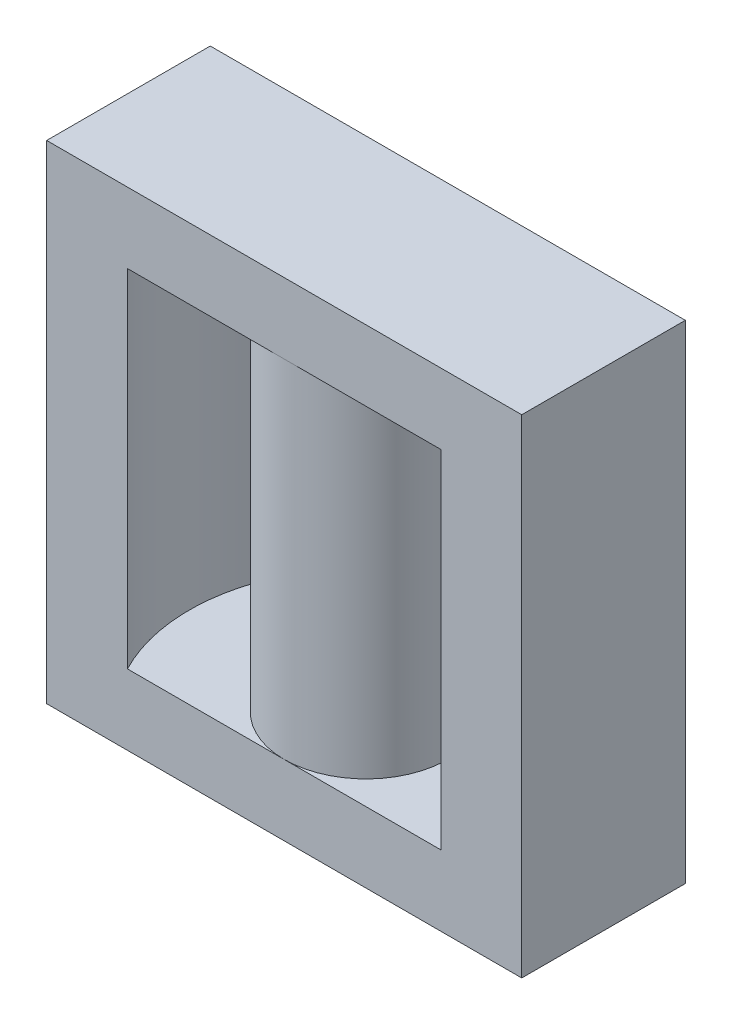
from build123d import *

# Parameters (mm, degrees)
BOSS_EXTRUDE1_DEPTH   = 49.8
SKETCH1_R             = 8.35
BOSS_EXTRUDE1_2_DEPTH = 49.8
BOSS_EXTRUDE1_3_DEPTH = 49.8
SKETCH2_W             = 48.5
SKETCH2_H             = 16.7
BOSS_EXTRUDE2_DEPTH   = 7.2
SKETCH3_W             = 48.5
SKETCH3_H             = 16.7
BOSS_EXTRUDE3_DEPTH   = 7.2


with BuildPart() as part:
    # Sketch1 → Boss-Extrude1 (new body)
    with BuildSketch(Plane(origin=(0, 0, 0), x_dir=(1, 0, 0), z_dir=(0, 1, 0))):
        with BuildLine():
            Line((-16.002499805, 8.35), (-24.25, 8.35))
            Line((-24.25, 8.35), (-24.25, -8.35))
            Line((-24.25, -8.35), (-16.002499805, -8.35))
            ThreePointArc((-16.002499805, -8.35), (-18.05, 0), (-16.002499805, 8.35))
        make_face()
    extrude(amount=BOSS_EXTRUDE1_DEPTH)



with BuildPart() as body_2:
    # Sketch1 → Boss-Extrude1 2 (new body)
    with BuildSketch(Plane(origin=(0, 0, 0), x_dir=(1, 0, 0), z_dir=(0, 1, 0))):
        Circle(SKETCH1_R)
    extrude(amount=BOSS_EXTRUDE1_2_DEPTH)


with BuildPart() as body_3:
    # Sketch1 → Boss-Extrude1 3 (new body)
    with BuildSketch(Plane(origin=(0, 0, 0), x_dir=(1, 0, 0), z_dir=(0, 1, 0))):
        with BuildLine():
            Line((24.25, 8.35), (16.002499805, 8.35))
            ThreePointArc((16.002499805, 8.35), (17.53065346, 4.298684597), (18.05, 0))
            ThreePointArc((18.05, 0), (17.53065346, -4.298684597), (16.002499805, -8.35))
            Line((16.002499805, -8.35), (24.25, -8.35))
            Line((24.25, -8.35), (24.25, 8.35))
        make_face()
    extrude(amount=BOSS_EXTRUDE1_3_DEPTH)


with BuildPart() as part_1:
    add(part.part)

    add(body_2.part)  # Boss-Extrude2 merges body 2

    add(body_3.part)  # Boss-Extrude2 merges body 3
    # Sketch2 → Boss-Extrude2 (add)
    with BuildSketch(Plane(origin=(0, 49.8, 0), x_dir=(1, 0, 0), z_dir=(0, 1, 0))):
        Rectangle(SKETCH2_W, SKETCH2_H)
    extrude(amount=-BOSS_EXTRUDE2_DEPTH)

    # Sketch3 → Boss-Extrude3 (add)
    with BuildSketch(Plane.XZ):
        Rectangle(SKETCH3_W, SKETCH3_H)
    extrude(amount=-BOSS_EXTRUDE3_DEPTH)


solid = part_1.part
